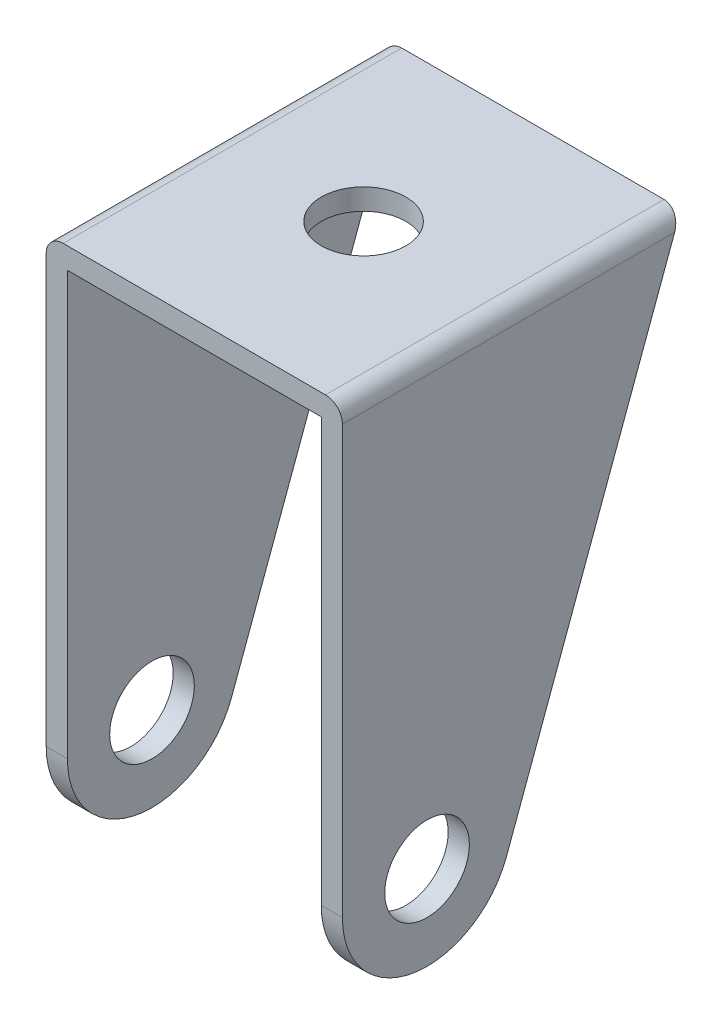
from build123d import *

# Parameters (mm, degrees)
SALIENTE_EXTRUIR1_DEPTH = 50.8
CROQUIS4_R              = 6.35
CORTAR_EXTRUIR4_DEPTH   = 50.8
REDONDEO1_R             = 2.54
CROQUIS7_R              = 6.35
CORTAR_EXTRUIR5_DEPTH   = 3.175


with BuildPart() as part:
    # Croquis3 → Saliente-Extruir1 (new body)
    with BuildSketch(Plane.XY):
        Polygon((0, 0), (0, 76.2), (38.1, 76.2), (38.1, 0), (41.275, 0), (41.275, 79.375), (-3.175, 79.375), (-3.175, 0), align=None)
    extrude(amount=SALIENTE_EXTRUIR1_DEPTH)

    # Croquis4 → Cortar-Extruir4 (cut)
    with BuildSketch(Plane(origin=(41.275, 0, 0), x_dir=(0, 0, -1), z_dir=(1, 0, 0))):
        with BuildLine():
            Line((-50.8, 0), (-38.099999933, 0))
            ThreePointArc((-38.099999933, 0), (-47.080256097, 3.719743855), (-50.8, 12.7))
            Line((-50.8, 12.7), (-50.8, 0))
        make_face()
        with Locations((-38.1, 12.7)):
            Circle(CROQUIS4_R)
        with BuildLine():
            Line((0, 0), (0, 79.375))
            Line((0, 79.375), (-26.18309853, 8.309389636))
            ThreePointArc((-26.18309853, 8.309389636), (-30.836073748, 2.282448685), (-38.099999933, 0))
            Line((-38.099999933, 0), (0, 0))
        make_face()
    extrude(amount=-CORTAR_EXTRUIR4_DEPTH, mode=Mode.SUBTRACT)

    # Redondeo1
    redondeo1_edges = [part.edges().sort_by_distance(p)[0] for p in [
        (-3.175, 79.375, 25.4),
        (41.275, 79.375, 25.4),
    ]]
    fillet(redondeo1_edges, radius=REDONDEO1_R)

    # Croquis7 → Cortar-Extruir5 (cut)
    with BuildSketch(Plane(origin=(0, 79.375, 0), x_dir=(1, 0, 0), z_dir=(0, 1, 0))):
        with Locations((19.05, -25.4)):
            Circle(CROQUIS7_R)
    extrude(amount=-CORTAR_EXTRUIR5_DEPTH, mode=Mode.SUBTRACT)


solid = part.part
